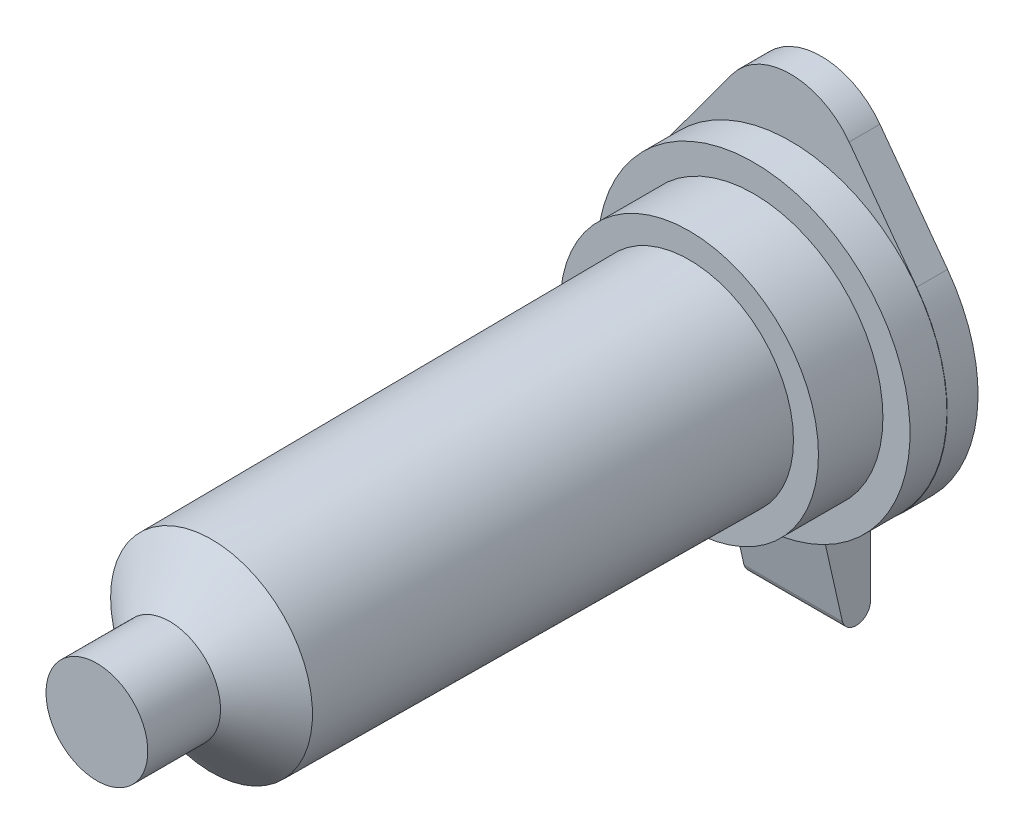
from build123d import *

# Parameters (mm, degrees)
BOSS_EXTRUDE1_DEPTH = 1.27
BOSS_EXTRUDE2_DEPTH = 2.03


with BuildPart() as part:
    # Sketch1 → Revolve1 (revolve)
    with BuildSketch(Plane(origin=(0, 0, 0), x_dir=(1, 0, 0), z_dir=(0, 1, 0))):
        Polygon((0, 0), (2.1, 0), (2.1, 3), (4.165, 4.73), (4.3, 24.44), (5.33, 24.44), (5.33, 27.1), (6.45, 27.1), (6.45, 28.62), (0, 28.62), align=None)
    revolve(axis=Axis((0, 0, -28.62), (0, 0, 1)))

    # Sketch2 → Boss-Extrude1 (add)
    with BuildSketch(Plane(origin=(0, 0, -28.62), x_dir=(-1, 0, 0), z_dir=(0, 0, -1))):
        with BuildLine():
            Line((5.206517503, 3.83254491), (2.416017403, 7.623443114))
            ThreePointArc((2.416017403, 7.623443114), (0, 8.845), (-2.416017403, 7.623443114))
            Line((-2.416017403, 7.623443114), (-5.206517503, 3.83254491))
            ThreePointArc((-5.206517503, 3.83254491), (0, -6.465), (5.206517503, 3.83254491))
        make_face()
    extrude(amount=BOSS_EXTRUDE1_DEPTH)

    # Sketch3 → Boss-Extrude2 (add, symmetric)
    with BuildSketch(Plane(origin=(0, 0, 0), x_dir=(0, 0, -1), z_dir=(1, 0, 0))):
        with BuildLine():
            Line((29.89, -5.667887402), (29.89, -9.59312184))
            ThreePointArc((29.89, -9.59312184), (29.385325952, -10.18), (28.729482517, -9.768914535))
            Line((28.729482517, -9.768914535), (27.803917735, -5.667887402))
            Line((27.803917735, -5.667887402), (29.89, -5.667887402))
        make_face()
    extrude(amount=BOSS_EXTRUDE2_DEPTH, both=True)


solid = part.part
